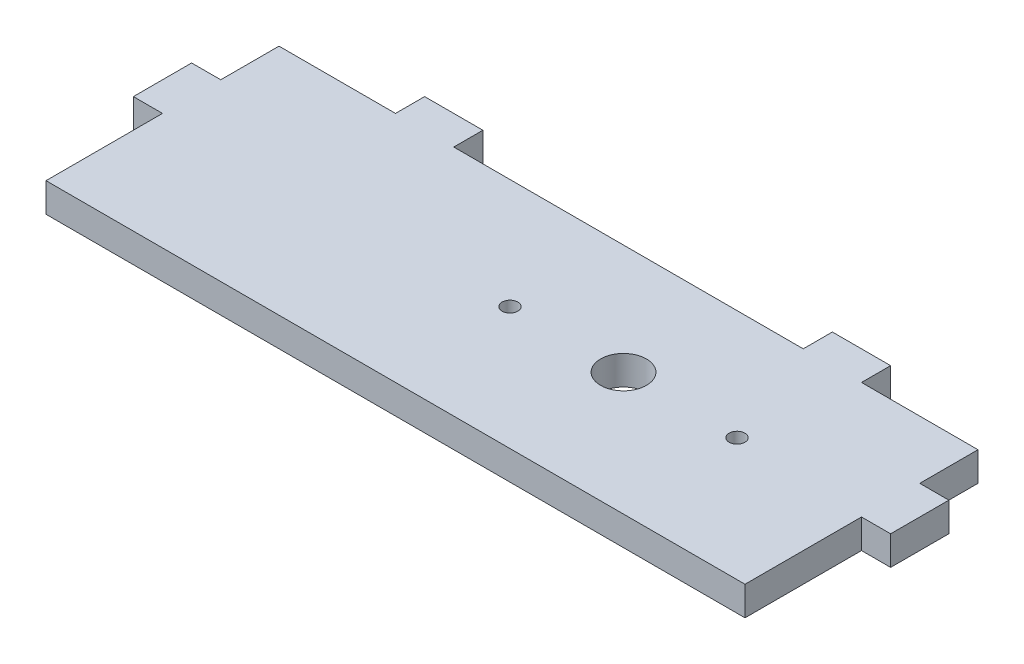
from build123d import *

# Parameters (mm, degrees)
SKETCH1_W           = 152.4
SKETCH1_H           = 50.8
SKETCH1_R           = 1.724999979
SKETCH1_R_2         = 5.000000033
SKETCH1_W_2         = 12.7
SKETCH1_H_2         = 6.35
SKETCH1_W_3         = 6.35
SKETCH1_H_3         = 12.7
BOSS_EXTRUDE1_DEPTH = 6.35


with BuildPart() as part:
    # Sketch1 → Boss-Extrude1 (new body)
    with BuildSketch(Plane(origin=(0, 0, 0), x_dir=(1, 0, 0), z_dir=(0, 1, 0))):
        with Locations((76.2, 25.4)):
            Rectangle(SKETCH1_W, SKETCH1_H)
        with Locations((74.35999987, 26.799999994)):
            Circle(SKETCH1_R, mode=Mode.SUBTRACT)
        with Locations((123.85999993, 26.799999994)):
            Circle(SKETCH1_R, mode=Mode.SUBTRACT)
        with Locations((99.1099999, 26.799999994)):
            Circle(SKETCH1_R_2, mode=Mode.SUBTRACT)
        with Locations((31.75, 53.975)):
            Rectangle(SKETCH1_W_2, SKETCH1_H_2)
        with Locations((-3.175, 31.75)):
            Rectangle(SKETCH1_W_3, SKETCH1_H_3)
        with Locations((155.575, 31.75)):
            Rectangle(SKETCH1_W_3, SKETCH1_H_3)
        with Locations((120.65, 53.975)):
            Rectangle(SKETCH1_W_2, SKETCH1_H_2)
    extrude(amount=BOSS_EXTRUDE1_DEPTH)


solid = part.part
